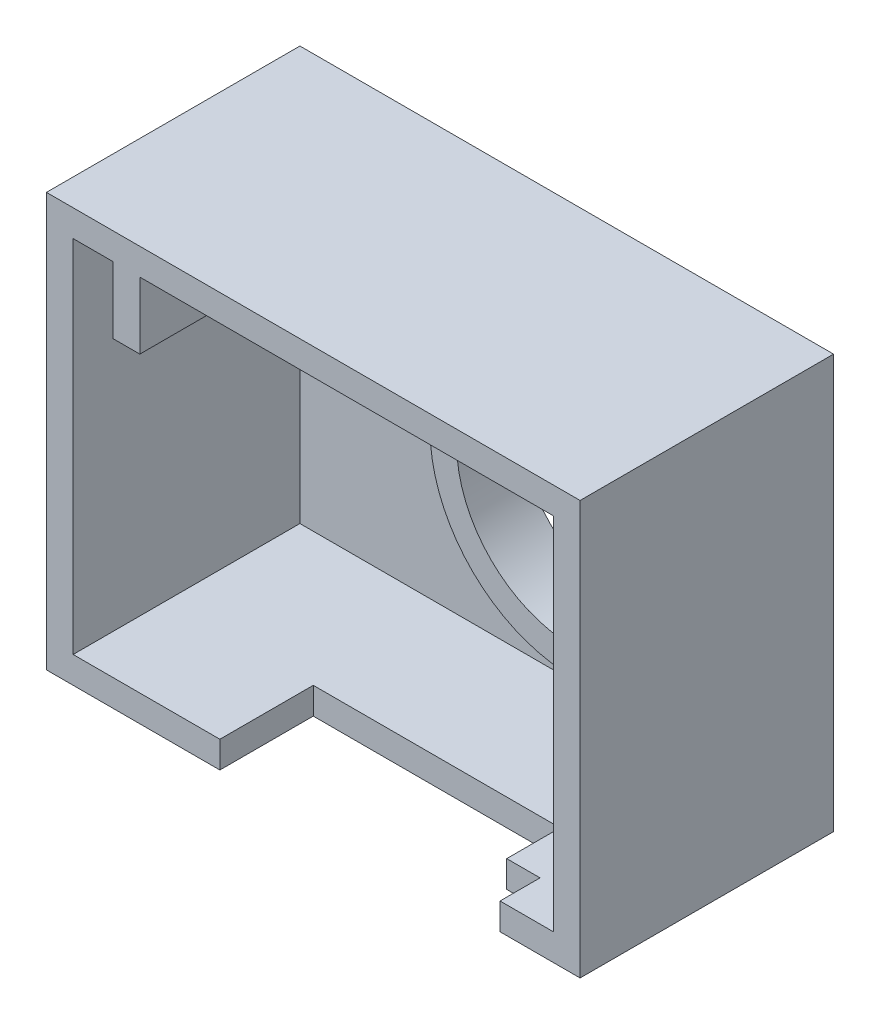
from build123d import *

# Parameters (mm, degrees)
SKETCH1_W                      = 40
SKETCH1_H                      = 31
SKETCH1_R                      = 8.75
BOSS_EXTRUDE1_DEPTH            = 19
SHELL1_T                       = -2
SKETCH2_R                      = 10.75
SKETCH2_R_2                    = 8.75
CUT_EXTRUDE1_DEPTH             = 14.5
SKETCH3_W                      = 2
SKETCH3_H                      = 5
BOSS_EXTRUDE2_DEPTH            = 17
SKETCH8_W                      = 7
SKETCH8_H                      = 7
BOSS_EXTRUDE3_DEPTH            = 3
CBORE_FOR_M3_SHCS1_D           = 3.4
CBORE_FOR_M3_SHCS1_CBORE_D     = 6.5
CBORE_FOR_M3_SHCS1_CBORE_DEPTH = 3
CUT_EXTRUDE3_REACH             = 46.125


with BuildPart() as part:
    # Sketch1 → Boss-Extrude1 (new body)
    with BuildSketch(Plane.XY):
        with Locations((-5, 0)):
            Rectangle(SKETCH1_W, SKETCH1_H)
        Circle(SKETCH1_R, mode=Mode.SUBTRACT)
    extrude(amount=-BOSS_EXTRUDE1_DEPTH)

    # Shell1
    shell1_openings = [part.faces().sort_by_distance(p)[0] for p in [
        (-5, -14.993936763, 0),
    ]]
    offset(amount=SHELL1_T, openings=shell1_openings, kind=Kind.INTERSECTION)

    # Sketch2 → Cut-Extrude1 (cut)
    with BuildSketch(Plane.XY):
        with Locations(Location((0, 0, 0), (0, 0, 180))):
            Circle(SKETCH2_R)
        Circle(SKETCH2_R_2, mode=Mode.SUBTRACT)
    extrude(amount=-CUT_EXTRUDE1_DEPTH, mode=Mode.SUBTRACT)

    # Sketch3 → Boss-Extrude2 (add)
    with BuildSketch(Plane.XY.offset(-17)):
        with Locations((-19, 11)):
            Rectangle(SKETCH3_W, SKETCH3_H)
    extrude(amount=BOSS_EXTRUDE2_DEPTH)

    # Sketch8 → Boss-Extrude3 (add)
    with BuildSketch(Plane.XY.offset(-17)):
        with Locations((-14.5, 10)):
            Rectangle(SKETCH8_W, SKETCH8_H)
    extrude(amount=BOSS_EXTRUDE3_DEPTH)

    # CBORE for M3 SHCS1 (through all)
    with Locations(Plane(origin=(0, 0, -19), x_dir=(-1, 0, 0), z_dir=(0, 0, -1))):
        with Locations((15, 10.5)):
            CounterBoreHole(CBORE_FOR_M3_SHCS1_D / 2, CBORE_FOR_M3_SHCS1_CBORE_D / 2, CBORE_FOR_M3_SHCS1_CBORE_DEPTH)

    # Sketch9 → Cut-Extrude3 (cut, up to next)
    with BuildSketch(Plane.XZ.offset(15.5), mode=Mode.PRIVATE) as cut_extrude3_sk1:
        Polygon((-12, 0), (6.5, 0), (9, 0), (9, -3), (6.5, -3), (6.5, -7), (-12, -7), align=None)
    cut_extrude3_tool1 = extrude(cut_extrude3_sk1.sketch, amount=-CUT_EXTRUDE3_REACH, mode=Mode.PRIVATE) & part.part
    add(cut_extrude3_tool1.solids().sort_by_distance((-2.175182, -15.5, -3.390511))[0], mode=Mode.SUBTRACT)


solid = part.part
